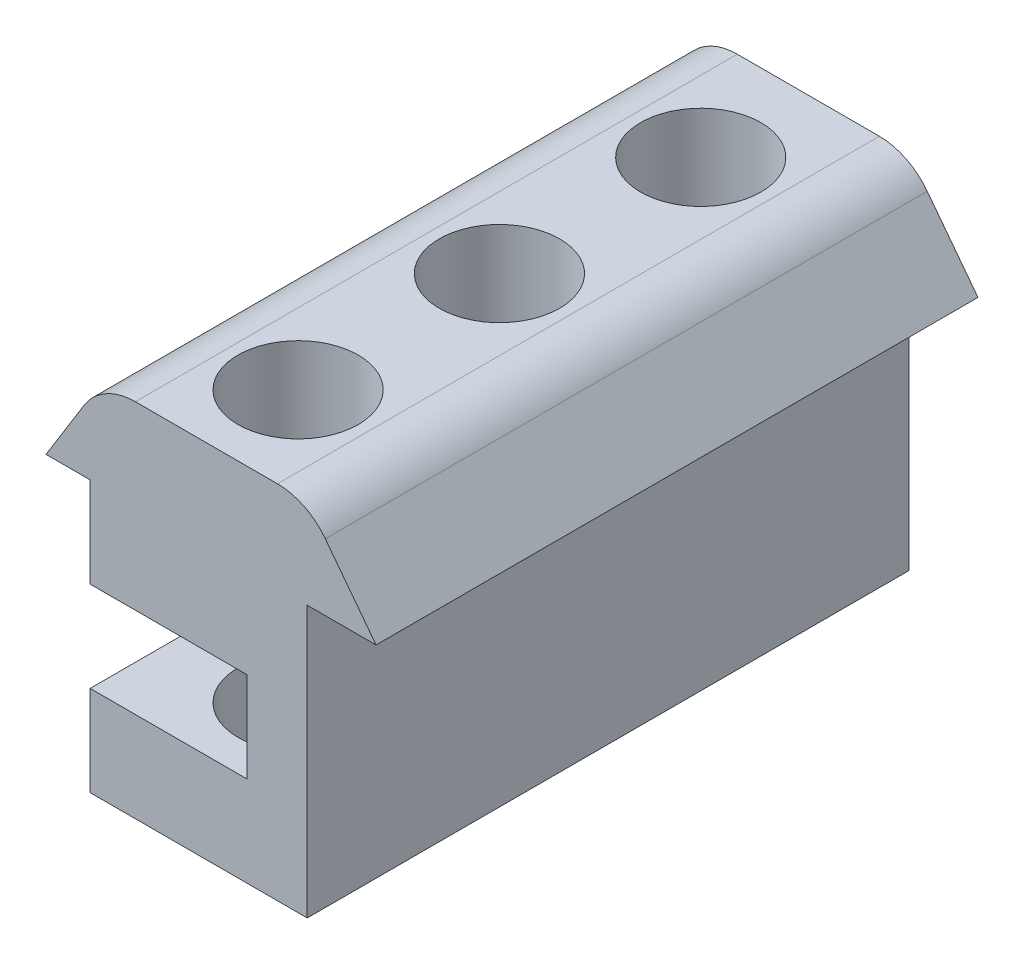
from build123d import *

# Parameters (mm, degrees)
RESSALTO_EXTRUS_O1_DEPTH   = 20
ESBO_O2_R                  = 2
CORTE_EXTRUS_O1_DEPTH      = 12
CORTE_EXTRUS_O1_DEPTH_BACK = 16


with BuildPart() as part:
    # Esboço1 → Ressalto-extrusão1 (new body)
    with BuildSketch(Plane.XY):
        with BuildLine():
            Line((3.196343382, -1.5), (3.583399622, -1.5))
            Line((3.583399622, -1.5), (5.483399622, -1.5))
            Line((5.483399622, -1.5), (3.796667791, 0.712536536))
            ThreePointArc((3.796667791, 0.712536536), (3.093538771, 1.292355025), (2.206147389, 1.5))
            Line((2.206147389, 1.5), (-2.51439317, 1.5))
            ThreePointArc((-2.51439317, 1.5), (-3.488374138, 1.24681455), (-4.215757297, 0.551361073))
            Line((-4.215757297, 0.551361073), (-5.483399622, -1.5))
            Line((-5.483399622, -1.5), (-4.016600378, -1.5))
            Line((-4.016600378, -1.5), (-4.016600378, -4.5))
            Line((-4.016600378, -4.5), (1.196343382, -4.5))
            Line((1.196343382, -4.5), (1.196343382, -7.5))
            Line((1.196343382, -7.5), (-4.016600378, -7.5))
            Line((-4.016600378, -7.5), (-4.016600378, -10.5))
            Line((-4.016600378, -10.5), (3.196343382, -10.5))
            Line((3.196343382, -10.5), (3.196343382, -7.5))
            Line((3.196343382, -7.5), (3.196343382, -4.5))
            Line((3.196343382, -4.5), (3.196343382, -1.5))
        make_face()
    extrude(amount=RESSALTO_EXTRUS_O1_DEPTH)

    # Esboço2 → Corte-extrusão1 (cut, two sides)
    with BuildSketch(Plane(origin=(0, 0, 0), x_dir=(1, 0, 0), z_dir=(0, 1, 0))) as corte_extrus_o1_sk:
        with Locations((-0.15412289, -3.574880423)):
            Circle(ESBO_O2_R)
        with Locations((-0.15412289, -10.26404601)):
            Circle(ESBO_O2_R)
        with Locations((-0.15412289, -16.953211597)):
            Circle(ESBO_O2_R)
    extrude(amount=CORTE_EXTRUS_O1_DEPTH, mode=Mode.SUBTRACT)
    extrude(corte_extrus_o1_sk.sketch, amount=-CORTE_EXTRUS_O1_DEPTH_BACK, mode=Mode.SUBTRACT)


solid = part.part
